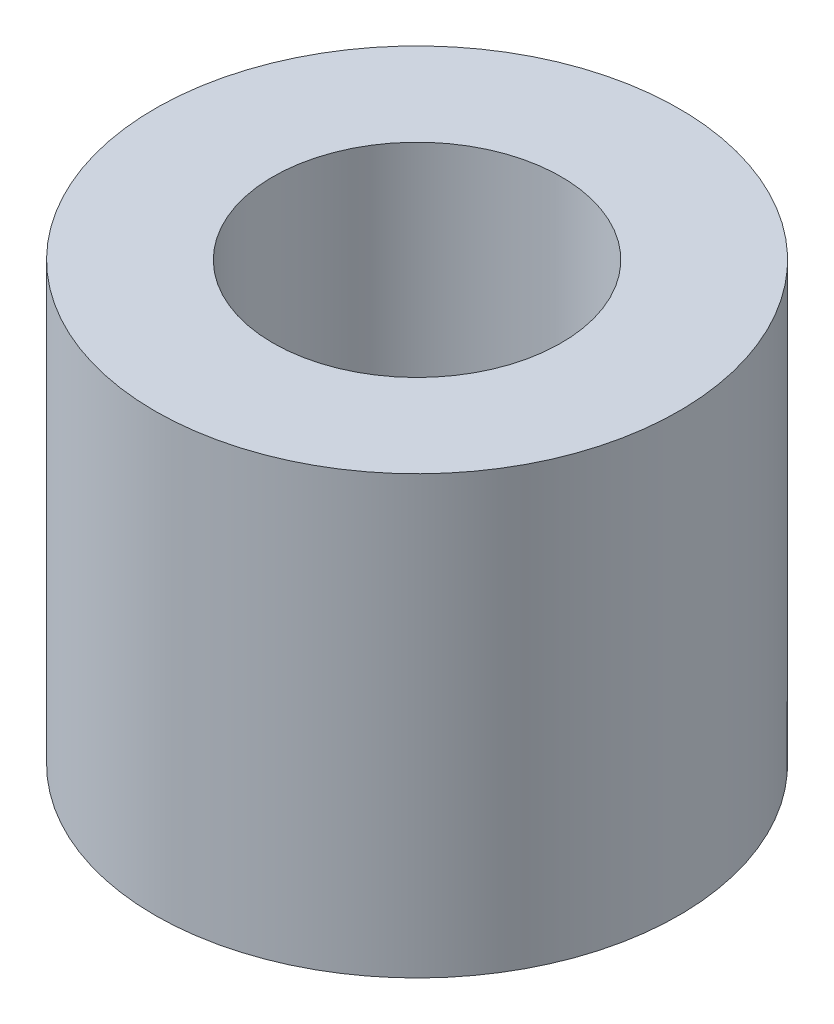
from build123d import *

# Parameters (mm, degrees)
SKETCH1_R           = 3
SKETCH1_R_2         = 1.65
BOSS_EXTRUDE1_DEPTH = 5


with BuildPart() as part:
    # Sketch1 → Boss-Extrude1 (new body)
    with BuildSketch(Plane(origin=(0, 0, 0), x_dir=(1, 0, 0), z_dir=(0, 1, 0))):
        Circle(SKETCH1_R)
        Circle(SKETCH1_R_2, mode=Mode.SUBTRACT)
    extrude(amount=BOSS_EXTRUDE1_DEPTH)


solid = part.part
